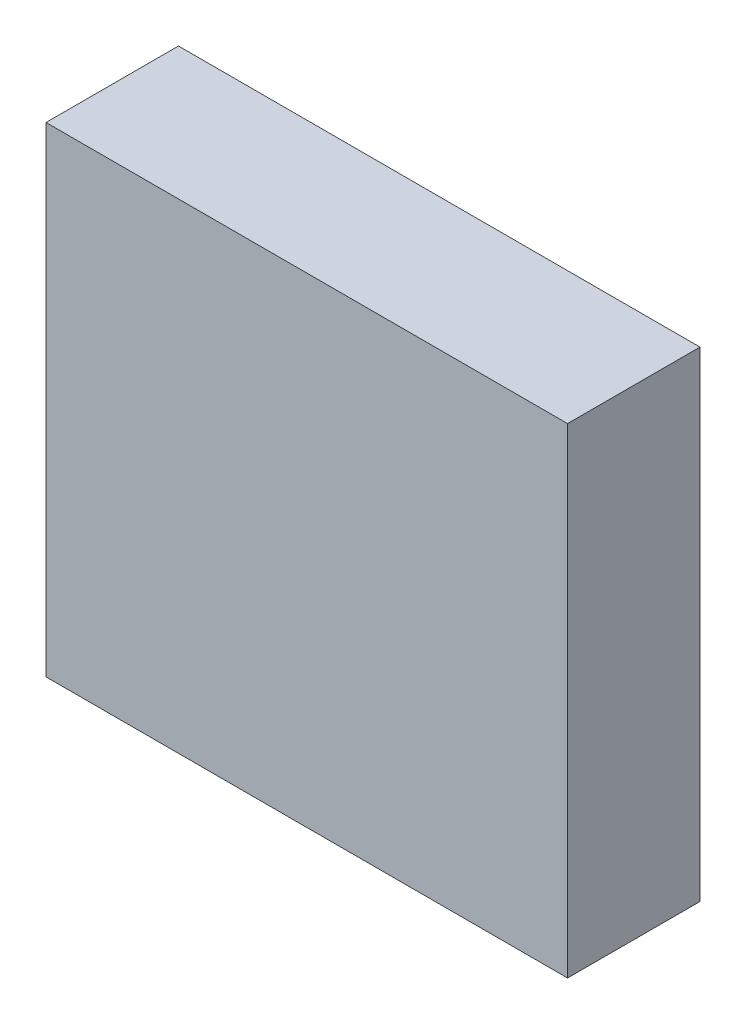
from build123d import *

# Parameters (mm, degrees)
SKETCH1_W           = 63
SKETCH1_H           = 58
BOSS_EXTRUDE1_DEPTH = 16


with BuildPart() as part:
    # Sketch1 → Boss-Extrude1 (new body)
    with BuildSketch(Plane.XY):
        with Locations((31.5, 29)):
            Rectangle(SKETCH1_W, SKETCH1_H)
    extrude(amount=BOSS_EXTRUDE1_DEPTH)


solid = part.part
